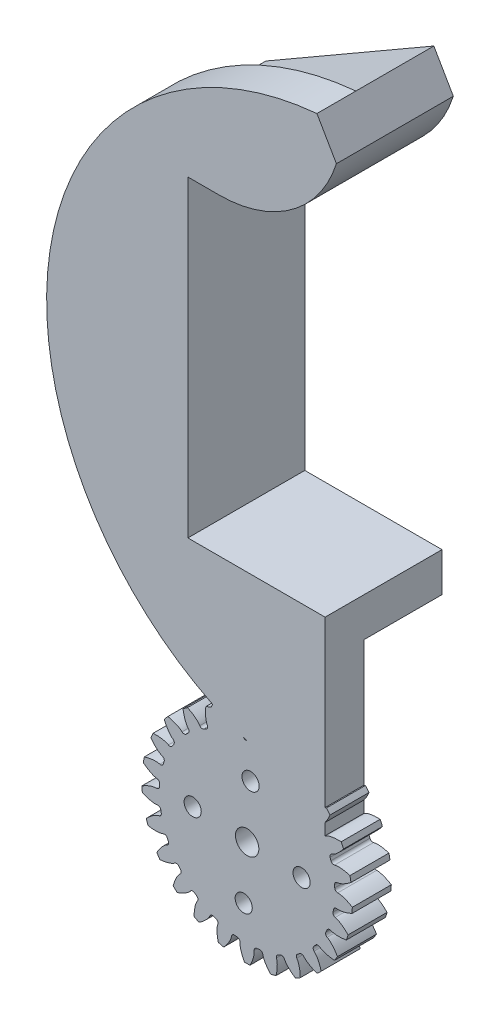
from build123d import *

# Parameters (mm, degrees)
SKETCH_1_R          = 13.5
LASHENA_DEPTH       = 5
CUT_EXTRUDEA_DEPTH  = 30
WWW_KYTOOL_CN_COUNT = 25
EXTRUDE_2_DEPTH     = 15
EXTRUDE_3_DEPTH     = 5
CUT_EXTRUDE_3_DEPTH = 10
SKETCH_7_R          = 1.5
SKETCH_7_R_2        = 1.1
CUT_EXTRUDE_4_DEPTH = 16.0000001


with BuildPart() as part:
    # Sketch 1 → LaShenA (new body)
    with BuildSketch(Plane.XY):
        Circle(SKETCH_1_R)
    extrude(amount=LASHENA_DEPTH)

    # SketchA → Cut-ExtrudeA (cut)
    with BuildSketch(Plane.XY.offset(5)):
        with BuildLine():
            ThreePointArc((0.168413676, 11.248739344), (0, 11.25), (-0.168413676, 11.248739344))
            ThreePointArc((-0.168413676, 11.248739344), (-0.431955465, 11.349569992), (-0.553318931, 11.60430908))
            add(Edge.make_bspline(
                [(-0.553318931, 11.60430908), (-0.556083603, 11.647298384), (-0.561050641, 11.7223845), (-0.572489313, 11.811624088), (-0.58477152, 11.87427273), (-0.59566003, 11.923918216), (-0.609744808, 11.980847357), (-0.62734241, 12.044939707), (-0.64885177, 12.116041497), (-0.674637893, 12.193990315), (-0.705068872, 12.278607345), (-0.740503482, 12.369700094), (-0.781294405, 12.467061823), (-0.827786595, 12.570472023), (-0.880317153, 12.679696595), (-0.939214753, 12.794488133), (-1.004799208, 12.914586205), (-1.077381014, 13.039717642), (-1.157260907, 13.169596858), (-1.244729425, 13.303926167), (-1.340066518, 13.442396124), (-1.443541, 13.584685884), (-1.595874213, 13.783191625), (-1.71844413, 13.930490189), (-1.804245931, 14.028565279)],
                knots=[0.117691322, 0.117691322, 0.117691322, 0.117691322, 0.158671831, 0.189773021, 0.203463493, 0.219643142, 0.238311966, 0.259469968, 0.283117146, 0.3092535, 0.337879031, 0.368993739, 0.402597623, 0.438690683, 0.47727292, 0.518344334, 0.561904924, 0.60795469, 0.656493633, 0.707521753, 0.761039049, 0.817045522, 0.875541172, 1, 1, 1, 1], degree=3))
            ThreePointArc((-1.804245931, 14.028565279), (0, 14.144113516), (1.804245931, 14.028565279))
            add(Edge.make_bspline(
                [(0.553318931, 11.60430908), (0.556083603, 11.647298384), (0.561050641, 11.7223845), (0.572489313, 11.811624088), (0.58477152, 11.87427273), (0.59566003, 11.923918216), (0.609744808, 11.980847357), (0.62734241, 12.044939707), (0.64885177, 12.116041497), (0.674637893, 12.193990315), (0.705068872, 12.278607345), (0.740503482, 12.369700094), (0.781294405, 12.467061823), (0.827786595, 12.570472023), (0.880317153, 12.679696595), (0.939214753, 12.794488133), (1.004799208, 12.914586205), (1.077381014, 13.039717642), (1.157260907, 13.169596858), (1.244729425, 13.303926167), (1.340066518, 13.442396124), (1.443541, 13.584685884), (1.595874213, 13.783191625), (1.71844413, 13.930490189), (1.804245931, 14.028565279)],
                knots=[0.117691322, 0.117691322, 0.117691322, 0.117691322, 0.158671831, 0.189773021, 0.203463493, 0.219643142, 0.238311966, 0.259469968, 0.283117146, 0.3092535, 0.337879031, 0.368993739, 0.402597623, 0.438690683, 0.47727292, 0.518344334, 0.561904924, 0.60795469, 0.656493633, 0.707521753, 0.761039049, 0.817045522, 0.875541172, 1, 1, 1, 1], degree=3))
            ThreePointArc((0.553318931, 11.60430908), (0.431955465, 11.349569992), (0.168413676, 11.248739344))
        make_face()
    cut_extrudea = extrude(amount=-CUT_EXTRUDEA_DEPTH, mode=Mode.SUBTRACT)

    # www.KYTool.cn: Cut-ExtrudeA ×25 about axis
    www_kytool_cn_axis = Axis((0, 0, -88.99), (0, 0, 1))
    for i in range(1, WWW_KYTOOL_CN_COUNT):
        add(cut_extrudea.rotate(www_kytool_cn_axis, i * 360 / WWW_KYTOOL_CN_COUNT), mode=Mode.SUBTRACT)

    # Sketch 3 → Extrude 2 (add)
    with BuildSketch(Plane.XY.offset(5)):
        with BuildLine():
            Line((10, 0), (10, 30))
            Line((10, 30), (-7.6, 30))
            Line((-7.6, 30), (-7.6, 70.1))
            Line((-7.6, 70.1), (-3.6, 70.1))
            ThreePointArc((-3.6, 70.1), (5.721742446, 73.143062491), (11.452558883, 81.1))
            Line((11.452558883, 81.1), (8.952558883, 85.430127019))
            Line((8.952558883, 85.430127019), (-12.6, 72.986751346))
            Line((-12.6, 72.986751346), (-12.6, 25))
            Line((-12.6, 25), (5, 25))
            Line((5, 25), (5, 8.660254038))
            ThreePointArc((5, 8.660254038), (8.660254038, 5), (10, 0))
        make_face()
    extrude(amount=-EXTRUDE_2_DEPTH)

    # Sketch 5 → Extrude 3 (add)
    with BuildSketch(Plane.XY.offset(5)):
        with BuildLine():
            Line((-4.426726917, 13.099160046), (-4.633843626, 12.679806515))
            add(Edge.make_bspline(
                [(-4.633843626, 12.679806515), (-4.552342618, 12.610459129), (-4.434592405, 12.505280913), (-4.286379018, 12.362117171), (-4.18495858, 12.258967329), (-4.091567405, 12.15895255), (-4.005972686, 12.062414637), (-3.927929426, 11.969685374), (-3.857180802, 11.881086133), (-3.793458524, 11.796927492), (-3.736483312, 11.717508818), (-3.685964978, 11.643118064), (-3.641603891, 11.5740309), (-3.603087991, 11.510512064), (-3.570104131, 11.452809639), (-3.542304151, 11.401171773), (-3.519411393, 11.355793854), (-3.491934971, 11.298167895), (-3.458662682, 11.214576614), (-3.435178535, 11.143084719), (-3.421809715, 11.102133549)],
                knots=[0.358992653, 0.358992653, 0.358992653, 0.358992653, 0.461197689, 0.509736632, 0.555786399, 0.599346989, 0.640418402, 0.679000639, 0.7150937, 0.748697584, 0.779812291, 0.808437822, 0.834574177, 0.858221354, 0.879379356, 0.898048181, 0.914227829, 0.927918301, 0.959019491, 1, 1, 1, 1], degree=3))
            ThreePointArc((-3.421809715, 11.102133549), (-3.24090807, 10.885579425), (-2.960570369, 10.853456735))
            ThreePointArc((-2.960570369, 10.853456735), (-2.797761231, 10.896560563), (-2.634325067, 10.937222291))
            ThreePointArc((-2.634325067, 10.937222291), (-2.404138491, 11.100425336), (-2.349938916, 11.377343194))
            add(Edge.make_bspline(
                [(-2.349938916, 11.377343194), (-2.357952107, 11.419669455), (-2.371814275, 11.493631855), (-2.382927953, 11.5829125), (-2.386611698, 11.64664738), (-2.388411601, 11.697441025), (-2.388927023, 11.756084374), (-2.387821402, 11.82253949), (-2.384670094, 11.896756647), (-2.379079173, 11.978669307), (-2.370925321, 12.06524737), (-2.363883865, 12.124422403), (-2.360050941, 12.153790082)],
                knots=[0.117691322, 0.117691322, 0.117691322, 0.117691322, 0.158671831, 0.189773021, 0.203463493, 0.219643142, 0.238311966, 0.259469968, 0.283117146, 0.3092535, 0.337879031, 0.366165499, 0.366165499, 0.366165499, 0.366165499], degree=3))
            ThreePointArc((-2.360050941, 12.153790082), (1.262824371, 10.836102718), (5, 9.890035154))
            Line((5, 9.890035154), (5, 25))
            Line((5, 25), (-12.6, 25))
            Line((-12.6, 25), (-12.6, 72.986751346))
            Line((-12.6, 72.986751346), (8.952558883, 85.430127019))
            ThreePointArc((8.952558883, 85.430127019), (-25.086434853, 54.323538728), (-4.426726917, 13.099160046))
        make_face()
    extrude(amount=-EXTRUDE_3_DEPTH)

    # Sketch 6 → Cut-Extrude 3 (cut)
    with BuildSketch(Plane(origin=(0, 0, -10), x_dir=(-1, 0, 0), z_dir=(0, 0, -1))):
        with BuildLine():
            Line((-5, 25), (-5, 8.660254038))
            ThreePointArc((-5, 8.660254038), (-8.049998244, 4.647668653), (-10, 0))
            Line((-10, 0), (-10, 25))
            Line((-10, 25), (-5, 25))
        make_face()
    extrude(amount=-CUT_EXTRUDE_3_DEPTH, mode=Mode.SUBTRACT)

    # Sketch 7 → Cut-Extrude 4 (cut, through all)
    with BuildSketch(Plane.XY.offset(5)):
        Circle(SKETCH_7_R)
        with Locations((-6.986187099, 0.439533637)):
            Circle(SKETCH_7_R_2)
        with Locations((0.439533637, 6.986187099)):
            Circle(SKETCH_7_R_2)
        with Locations((6.986187099, -0.439533637)):
            Circle(SKETCH_7_R_2)
        with Locations((-0.439533637, -6.986187099)):
            Circle(SKETCH_7_R_2)
    extrude(amount=-CUT_EXTRUDE_4_DEPTH, mode=Mode.SUBTRACT)


solid = part.part
